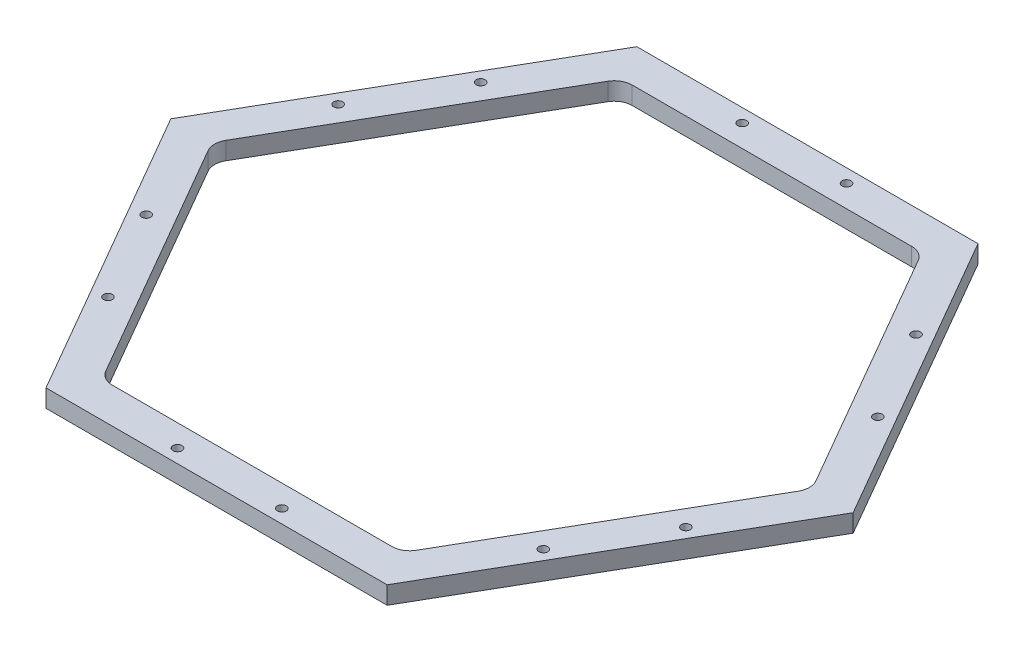
from build123d import *

# Parameters (mm, degrees)
BOSS_EXTRUDE1_DEPTH            = 3.175
M2X0_4_TAPPED_HOLE1_AT_2_COUNT = 2
M2X0_4_TAPPED_HOLE1_AT_2_PITCH = 18.662705418
CIRPATTERN1_COUNT              = 6


with BuildPart() as part:
    # Sketch1 → Boss-Extrude1 (new body)
    with BuildSketch(Plane(origin=(0, 0, 0), x_dir=(1, 0, 0), z_dir=(0, 1, 0))):
        Polygon((60.998522628, 0), (30.499261314, 52.826270189), (-30.499261314, 52.826270189), (-60.998522628, 0), (-30.499261314, -52.826270189), (30.499261314, -52.826270189), align=None)
        with BuildLine():
            Line((52.749630657, 1.5875), (27.749630657, 44.888770189))
            ThreePointArc((27.749630657, 44.888770189), (26.5875, 46.050900846), (25, 46.476270189))
            Line((25, 46.476270189), (-25, 46.476270189))
            ThreePointArc((-25, 46.476270189), (-26.5875, 46.050900846), (-27.749630657, 44.888770189))
            Line((-27.749630657, 44.888770189), (-52.749630657, 1.5875))
            ThreePointArc((-52.749630657, 1.5875), (-53.175, 0), (-52.749630657, -1.5875))
            Line((-52.749630657, -1.5875), (-27.749630657, -44.888770189))
            ThreePointArc((-27.749630657, -44.888770189), (-26.5875, -46.050900846), (-25, -46.476270189))
            Line((-25, -46.476270189), (25, -46.476270189))
            ThreePointArc((25, -46.476270189), (26.5875, -46.050900846), (27.749630657, -44.888770189))
            Line((27.749630657, -44.888770189), (52.749630657, -1.5875))
            ThreePointArc((52.749630657, -1.5875), (53.175, 0), (52.749630657, 1.5875))
        make_face(mode=Mode.SUBTRACT)
    extrude(amount=BOSS_EXTRUDE1_DEPTH)

    # Sketch2 → M2x0.4 Tapped Hole1 (revolve, cut)
    with BuildSketch(Plane(origin=(9.408369434, 3.175, -50.410234914), x_dir=(0, 0, 1), z_dir=(1, 0, 0))):
        Polygon((0, 0), (0, 6.576688495), (0.8, 6.096), (0.8, 0), align=None)
    m2x0_4_tapped_hole1 = revolve(axis=Axis((9.408369434, 9.525, -50.410234914), (0, -1, 0)), mode=Mode.SUBTRACT)

    # M2x0.4 Tapped Hole1 at 2: M2x0.4 Tapped Hole1 ×2
    with Locations(*[(-i * M2X0_4_TAPPED_HOLE1_AT_2_PITCH, 0, 0) for i in range(1, M2X0_4_TAPPED_HOLE1_AT_2_COUNT)]):
        add(m2x0_4_tapped_hole1, mode=Mode.SUBTRACT)

    # CirPattern1: M2x0.4 Tapped Hole1 ×6 about axis
    cirpattern1_axis = Axis((0, 0, 0), (0, 1, 0))
    for i in range(1, CIRPATTERN1_COUNT):
        add(m2x0_4_tapped_hole1.rotate(cirpattern1_axis, i * 360 / CIRPATTERN1_COUNT), mode=Mode.SUBTRACT)

    # CirPattern1 copy 1 sketch → CirPattern1 copy 1 (revolve, cut)
    with BuildSketch(Plane(origin=(-48.283712038, 3.175, -17.1906274), x_dir=(0.866025404, 0, 0.5), z_dir=(0.5, 0, -0.866025404))):
        Polygon((0, 0), (0, 6.576688495), (0.8, 6.096), (0.8, 0), align=None)
    revolve(axis=Axis((-48.283712038, 9.525, -17.1906274), (0, -1, 0)), mode=Mode.SUBTRACT)

    # CirPattern1 copy 2 sketch → CirPattern1 copy 2 (revolve, cut)
    with BuildSketch(Plane(origin=(-39.029376054, 3.175, 33.219607514), x_dir=(0.866025404, 0, -0.5), z_dir=(-0.5, 0, -0.866025404))):
        Polygon((0, 0), (0, 6.576688495), (0.8, 6.096), (0.8, 0), align=None)
    revolve(axis=Axis((-39.029376054, 9.525, 33.219607514), (0, -1, 0)), mode=Mode.SUBTRACT)

    # CirPattern1 copy 3 sketch → CirPattern1 copy 3 (revolve, cut)
    with BuildSketch(Plane(origin=(9.254335984, 3.175, 50.410234914), x_dir=(0, 0, -1), z_dir=(-1, 0, 0))):
        Polygon((0, 0), (0, 6.576688495), (0.8, 6.096), (0.8, 0), align=None)
    revolve(axis=Axis((9.254335984, 9.525, 50.410234914), (0, -1, 0)), mode=Mode.SUBTRACT)

    # CirPattern1 copy 4 sketch → CirPattern1 copy 4 (revolve, cut)
    with BuildSketch(Plane(origin=(48.283712038, 3.175, 17.1906274), x_dir=(-0.866025404, 0, -0.5), z_dir=(-0.5, 0, 0.866025404))):
        Polygon((0, 0), (0, 6.576688495), (0.8, 6.096), (0.8, 0), align=None)
    revolve(axis=Axis((48.283712038, 9.525, 17.1906274), (0, -1, 0)), mode=Mode.SUBTRACT)

    # CirPattern1 copy 5 sketch → CirPattern1 copy 5 (revolve, cut)
    with BuildSketch(Plane(origin=(39.029376054, 3.175, -33.219607514), x_dir=(-0.866025404, 0, 0.5), z_dir=(0.5, 0, 0.866025404))):
        Polygon((0, 0), (0, 6.576688495), (0.8, 6.096), (0.8, 0), align=None)
    revolve(axis=Axis((39.029376054, 9.525, -33.219607514), (0, -1, 0)), mode=Mode.SUBTRACT)


solid = part.part
